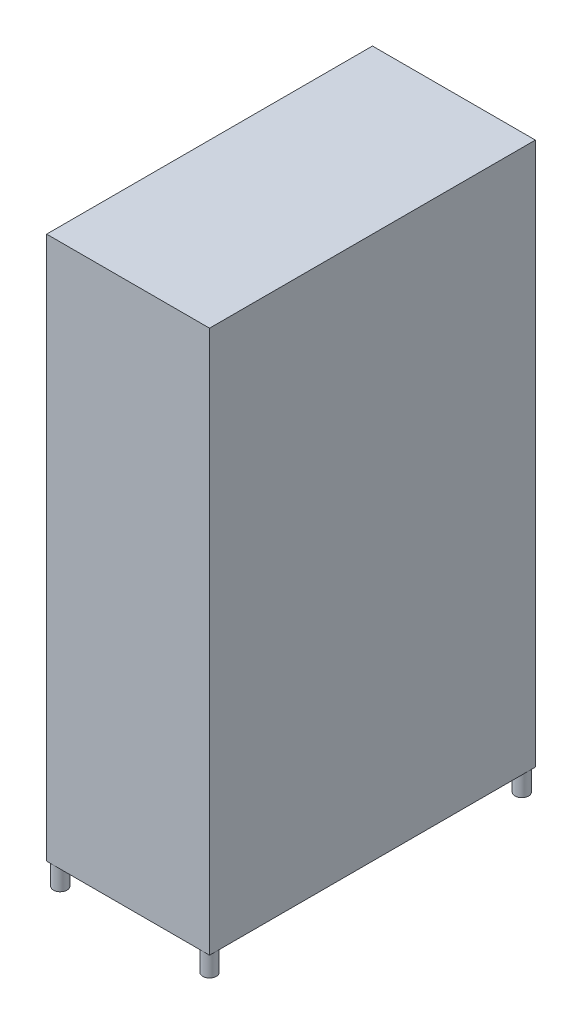
from build123d import *

# Parameters (mm, degrees)
SKETCH_1_W               = 600
SKETCH_1_H               = 1200
EXTRUDE_1_DEPTH          = 2000
SKETCH_2_R               = 25
EXTRUDE_2_DEPTH          = 80
MIRROR_2_COPY_1_SKETCH_R = 25
MIRROR_2_COPY_1_DEPTH    = 80


with BuildPart() as part:
    # 草图1 → 凸台-拉伸1 (new body)
    with BuildSketch(Plane(origin=(0, 0, 0), x_dir=(1, 0, 0), z_dir=(0, 1, 0))):
        Rectangle(SKETCH_1_W, SKETCH_1_H)
    extrude(amount=EXTRUDE_1_DEPTH)

    # 草图2 → 凸台-拉伸2 (add)
    with BuildSketch(Plane.XZ):
        with Locations((275, 575)):
            Circle(SKETCH_2_R)
    extrude_2 = extrude(amount=EXTRUDE_2_DEPTH)

    # 镜向1: 凸台-拉伸2 across plane
    add(extrude_2.mirror(Plane(origin=(0, 0, 0), x_dir=(0, 0, 1), z_dir=(1, 0, 0))))

    # 镜向2: 凸台-拉伸2 across plane
    add(extrude_2.mirror(Plane.XY))

    # 镜向2 copy 1 sketch → 镜向2 copy 1 (add)
    with BuildSketch(Plane(origin=(0, 0, 0), x_dir=(-1, 0, 0), z_dir=(0, -1, 0))):
        with Locations((275, 575)):
            Circle(MIRROR_2_COPY_1_SKETCH_R)
    extrude(amount=MIRROR_2_COPY_1_DEPTH)


solid = part.part
